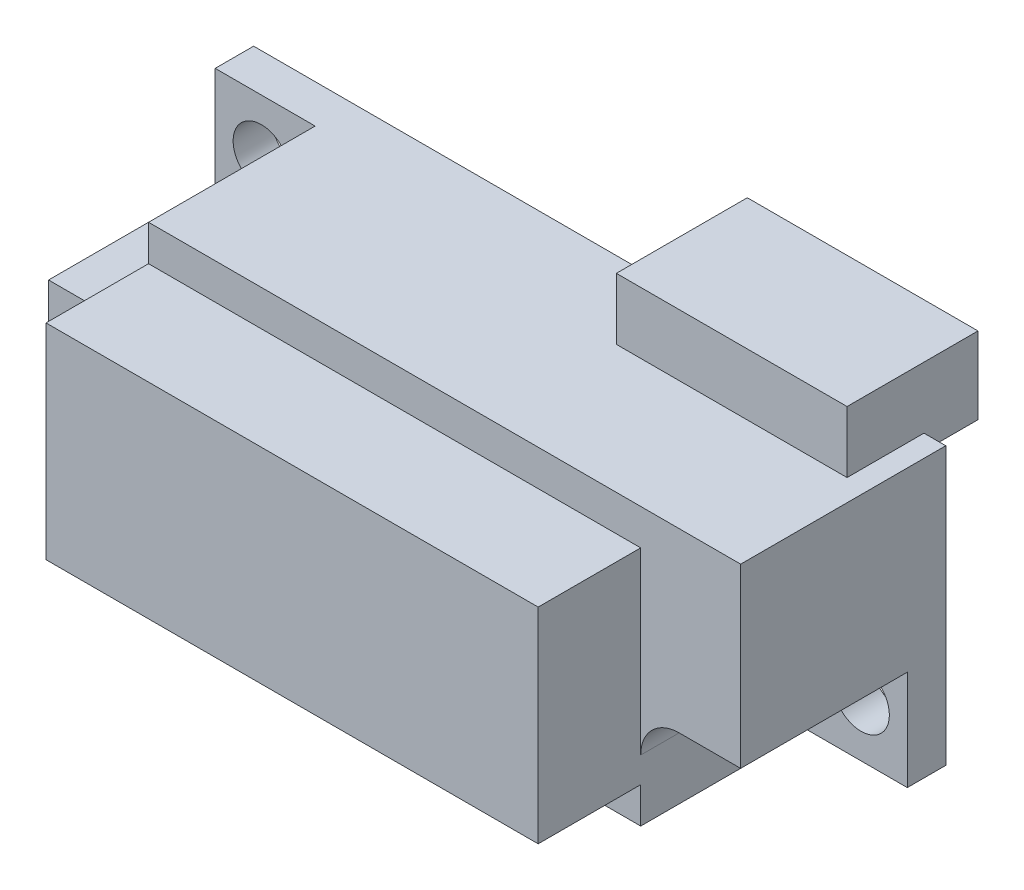
from build123d import *

# Parameters (mm, degrees)
SKETCH_1_W           = 27
SKETCH_1_H           = 10.8
EXTRUDE_1_DEPTH      = 12
SKETCH_2_W           = 3.9
SKETCH_2_H           = 3.9
CUT_EXTRUDE_2_DEPTH  = 10.5
FILLET_3_R           = 1.5
FILLET_4_R           = 1.5
SKETCH_3_R           = 1.1
CUT_EXTRUDE_3_DEPTH  = 2.1
SKETCH_4_W           = 27
SKETCH_4_H           = 10.8
SKETCH_4_W_2         = 19.2
SKETCH_4_H_2         = 8
CUT_EXTRUDE_4_DEPTH  = 4
SKETCH_5_W           = 9
SKETCH_5_H           = 3
EXTRUDE_2_DEPTH      = 2.108
EXTRUDE_2_DEPTH_BACK = 3


with BuildPart() as part:
    # 스케치1 → 보스-돌출1 (new body)
    with BuildSketch(Plane.XY):
        with Locations((-12.645283423, 9.45123242)):
            Rectangle(SKETCH_1_W, SKETCH_1_H)
    extrude(amount=EXTRUDE_1_DEPTH)

    # 스케치2 → 컷-돌출2 (cut)
    with BuildSketch(Plane.XY.offset(12)):
        with Locations((-24.195283423, 12.90123242)):
            Rectangle(SKETCH_2_W, SKETCH_2_H)
        with Locations((-1.095283423, 6.00123242)):
            Rectangle(SKETCH_2_W, SKETCH_2_H)
    extrude(amount=-CUT_EXTRUDE_2_DEPTH, mode=Mode.SUBTRACT)

    # 필렛3
    fillet_3_edges = [part.edges().sort_by_distance(p)[0] for p in [
        (-22.245283423, 10.95123242, 6.75),
    ]]
    fillet(fillet_3_edges, radius=FILLET_3_R)

    # 필렛4
    fillet_4_edges = [part.edges().sort_by_distance(p)[0] for p in [
        (-3.045283423, 7.95123242, 6.75),
    ]]
    fillet(fillet_4_edges, radius=FILLET_4_R)

    # 스케치3 → 컷-돌출3 (cut)
    with BuildSketch(Plane.XY.offset(1.5)):
        with Locations((-24.345283423, 12.75123242)):
            Circle(SKETCH_3_R)
        with Locations((-0.945283423, 6.15123242)):
            Circle(SKETCH_3_R)
    extrude(amount=-CUT_EXTRUDE_3_DEPTH, mode=Mode.SUBTRACT)

    # 스케치4 → 컷-돌출4 (cut)
    with BuildSketch(Plane.XY.offset(12)):
        with Locations((-12.645283423, 9.45123242)):
            Rectangle(SKETCH_4_W, SKETCH_4_H)
        with Locations((-12.645283423, 9.45123242)):
            Rectangle(SKETCH_4_W_2, SKETCH_4_H_2, mode=Mode.SUBTRACT)
    extrude(amount=-CUT_EXTRUDE_4_DEPTH, mode=Mode.SUBTRACT)

    # 스케치5 → 보스-돌출2 (add, two sides)
    with BuildSketch(Plane(origin=(0, 0, 0), x_dir=(-1, 0, 0), z_dir=(0, 0, -1))) as extrude_2_sk:
        with Locations((4.495283423, 15.75123242)):
            Rectangle(SKETCH_5_W, SKETCH_5_H)
    extrude(amount=EXTRUDE_2_DEPTH)
    extrude(extrude_2_sk.sketch, amount=-EXTRUDE_2_DEPTH_BACK)


solid = part.part
